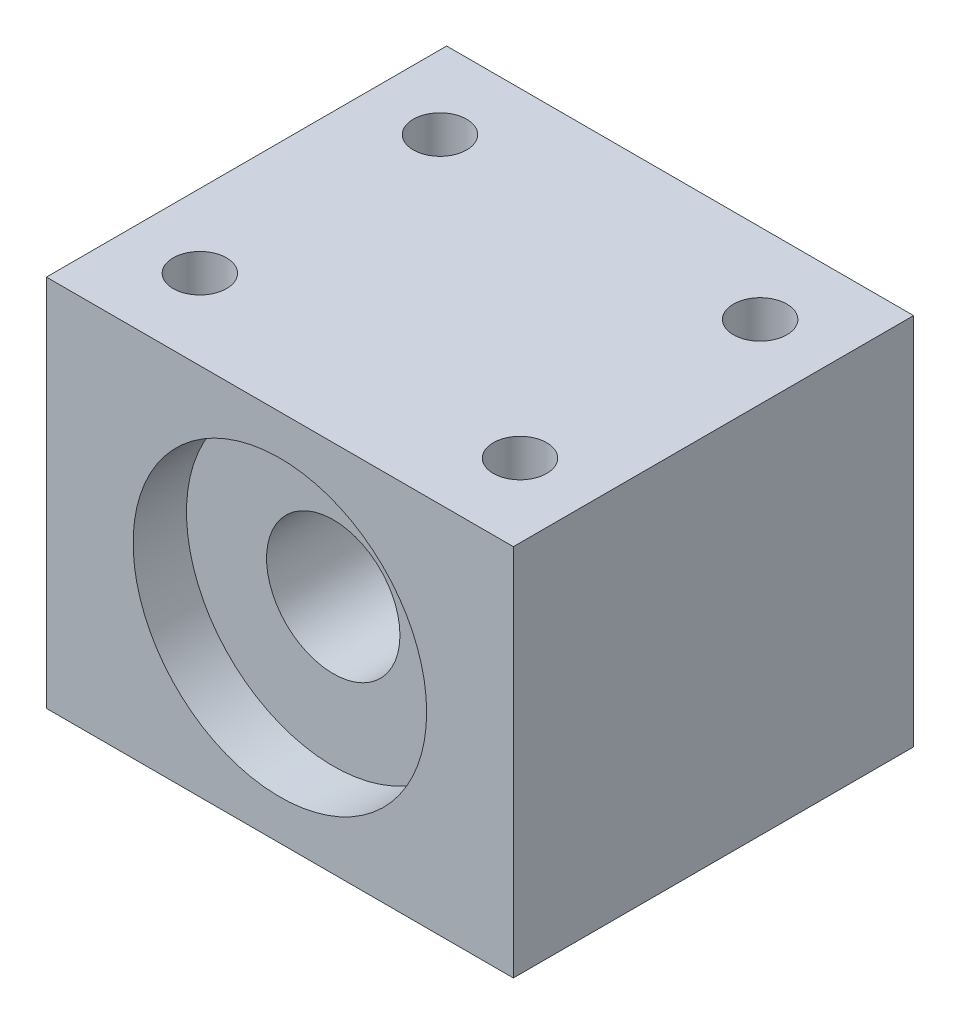
from build123d import *

# Parameters (mm, degrees)
SKETCH1_W           = 35
SKETCH1_H           = 30
SKETCH1_R           = 2
BOSS_EXTRUDE1_DEPTH = 28
SKETCH2_R           = 11
CUT_EXTRUDE1_DEPTH  = 4
SKETCH3_R           = 5
CUT_EXTRUDE2_DEPTH  = 27


with BuildPart() as part:
    # Sketch1 → Boss-Extrude1 (new body)
    with BuildSketch(Plane(origin=(0, 0, 0), x_dir=(1, 0, 0), z_dir=(0, 1, 0))):
        Rectangle(SKETCH1_W, SKETCH1_H)
        with Locations((-12, 9)):
            Circle(SKETCH1_R, mode=Mode.SUBTRACT)
        with Locations((-12, -9)):
            Circle(SKETCH1_R, mode=Mode.SUBTRACT)
        with Locations((12, -9)):
            Circle(SKETCH1_R, mode=Mode.SUBTRACT)
        with Locations((12, 9)):
            Circle(SKETCH1_R, mode=Mode.SUBTRACT)
    extrude(amount=BOSS_EXTRUDE1_DEPTH)

    # Sketch2 → Cut-Extrude1 (cut)
    with BuildSketch(Plane.XY.offset(15)):
        with Locations((0, 14)):
            Circle(SKETCH2_R)
    extrude(amount=-CUT_EXTRUDE1_DEPTH, mode=Mode.SUBTRACT)

    # Sketch3 → Cut-Extrude2 (cut, through all)
    with BuildSketch(Plane.XY.offset(11)):
        with Locations((0, 14)):
            Circle(SKETCH3_R)
    extrude(amount=-CUT_EXTRUDE2_DEPTH, mode=Mode.SUBTRACT)


solid = part.part
